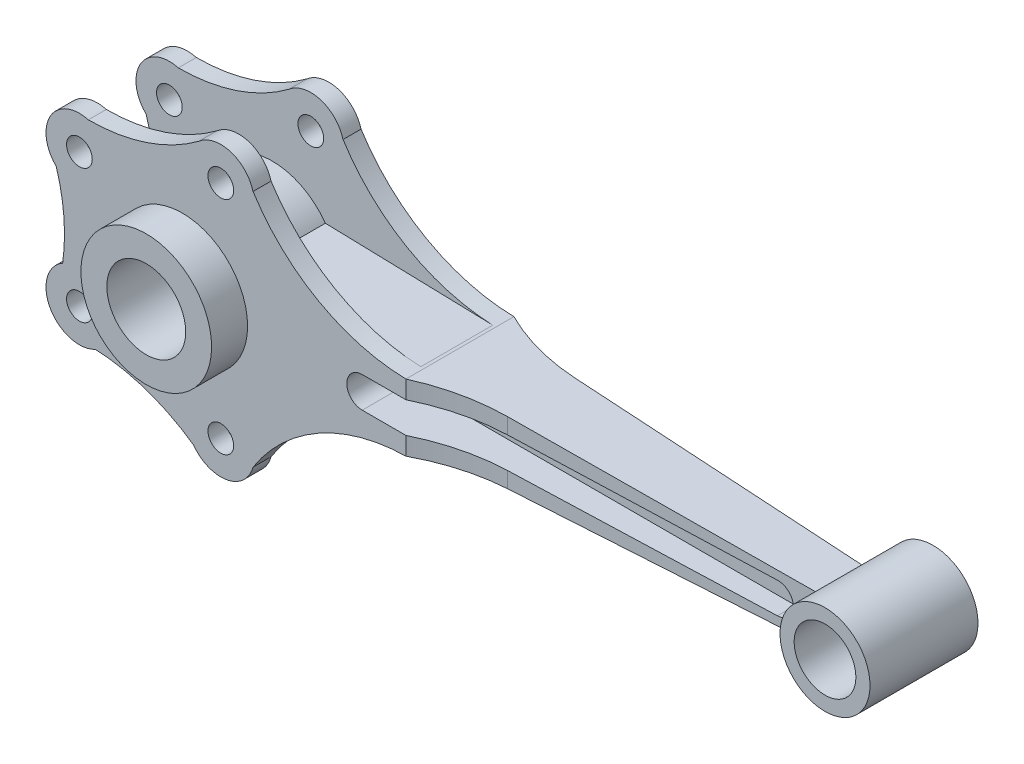
from build123d import *

# Parameters (mm, degrees)
SKETCH1_R           = 25.416099274
SKETCH1_R_2         = 15.345879333
BOSS_EXTRUDE3_DEPTH = 35
BOSS_EXTRUDE4_DEPTH = 21
CUT_EXTRUDE1_DEPTH  = 21
SKETCH1_7_R         = 17.5
SKETCH1_7_R_2       = 12
BOSS_EXTRUDE5_DEPTH = 21
BOSS_EXTRUDE6_START = 14
SKETCH1_8_R         = 5
BOSS_EXTRUDE6_DEPTH = 7
CUT_EXTRUDE2_DEPTH  = 18.5


with BuildPart() as part:
    # Sketch1 → Boss-Extrude3 (new body, symmetric)
    with BuildSketch(Plane.XY):
        Circle(SKETCH1_R)
        Circle(SKETCH1_R_2, mode=Mode.SUBTRACT)
    extrude(amount=BOSS_EXTRUDE3_DEPTH, both=True)

    # Sketch1_6 → Boss-Extrude4 (add, symmetric)
    with BuildSketch(Plane.XY):
        with BuildLine():
            ThreePointArc((234.99166898, -9), (232.5, 0), (234.99166898, 9))
            Line((234.99166898, 9), (87, 13))
            ThreePointArc((87, 13), (86.400314561, 13.01370903), (85.800764144, 13.032413604))
            Line((85.800764144, 13.032413604), (20.667586541, 14.792868853))
            ThreePointArc((20.667586541, 14.792868853), (24.199871215, 7.768161657), (25.416099274, 0))
            ThreePointArc((25.416099274, 0), (24.199871215, -7.768161657), (20.667586541, -14.792868853))
            Line((20.667586541, -14.792868853), (85.800764144, -13.032413604))
            ThreePointArc((85.800764144, -13.032413604), (86.400314561, -13.01370903), (87, -13))
            Line((87, -13), (234.99166898, -9))
        make_face()
    extrude(amount=BOSS_EXTRUDE4_DEPTH, both=True)

    # Sketch2 → Cut-Extrude1 (cut, symmetric)
    with BuildSketch(Plane(origin=(0, 0, 0), x_dir=(1, 0, 0), z_dir=(0, 1, 0))):
        with BuildLine():
            Line((118.656620919, 13.062509397), (234.99166898, 9))
            Line((234.99166898, 9), (234.99166898, 21))
            Line((234.99166898, 21), (87, 21))
            ThreePointArc((87, 21), (102.408517533, 15.35701958), (118.656620919, 13.062509397))
        make_face()
        with BuildLine():
            Line((87, -21), (234.99166898, -21))
            Line((234.99166898, -21), (234.99166898, -9))
            Line((234.99166898, -9), (118.656620919, -13.062509397))
            ThreePointArc((118.656620919, -13.062509397), (102.408517533, -15.35701958), (87, -21))
        make_face()
    extrude(amount=CUT_EXTRUDE1_DEPTH, both=True, mode=Mode.SUBTRACT)

    # Sketch1_7 → Boss-Extrude5 (add, symmetric)
    with BuildSketch(Plane.XY):
        with Locations((250, 0)):
            Circle(SKETCH1_7_R)
        with Locations((250, 0)):
            Circle(SKETCH1_7_R_2, mode=Mode.SUBTRACT)
    extrude(amount=BOSS_EXTRUDE5_DEPTH, both=True)

    # Sketch1_8 → Boss-Extrude6 (add)
    with BuildSketch(Plane.XY.offset(BOSS_EXTRUDE6_START)):
        with BuildLine():
            Line((20.667586541, 14.792868853), (85.800764144, 13.032413604))
            ThreePointArc((85.800764144, 13.032413604), (52.537254482, 22.523369258), (27.53882285, 46.431897657))
            ThreePointArc((27.53882285, 46.431897657), (18.775996279, 55.439527809), (6.484634563, 52.82285862))
            ThreePointArc((6.484634563, 52.82285862), (-13.863951623, 42.202436765), (-36.520978816, 38.525829777))
            ThreePointArc((-36.520978816, 38.525829777), (-51.292032009, 32.441274184), (-49.011059213, 16.629791258))
            ThreePointArc((-49.011059213, 16.629791258), (-46.024075038, 1.080135069), (-46.508202044, -14.746409188))
            ThreePointArc((-46.508202044, -14.746409188), (-51.333950201, -32.367226465), (-33.774741186, -37.412543656))
            ThreePointArc((-33.774741186, -37.412543656), (-13.740515927, -41.247010721), (4.414359967, -50.546139748))
            ThreePointArc((4.414359967, -50.546139748), (17.277164415, -55.799004736), (27.53882285, -46.431897657))
            ThreePointArc((27.53882285, -46.431897657), (52.537254482, -22.523369258), (85.800764144, -13.032413604))
            Line((85.800764144, -13.032413604), (20.667586541, -14.792868853))
            ThreePointArc((20.667586541, -14.792868853), (-25.416099274, 0), (20.667586541, 14.792868853))
        make_face()
        with Locations((15, -43)):
            Circle(SKETCH1_8_R, mode=Mode.SUBTRACT)
        with Locations((-40, -26)):
            Circle(SKETCH1_8_R, mode=Mode.SUBTRACT)
        with Locations((-40, 26)):
            Circle(SKETCH1_8_R, mode=Mode.SUBTRACT)
        with Locations((15, 43)):
            Circle(SKETCH1_8_R, mode=Mode.SUBTRACT)
    boss_extrude6 = extrude(amount=BOSS_EXTRUDE6_DEPTH)

    # Mirror1: Boss-Extrude6 across plane
    add(boss_extrude6.mirror(Plane.XY))

    # Sketch3 → Cut-Extrude2 (cut)
    with BuildSketch(Plane.XY.offset(21)):
        with BuildLine():
            Line((70, 6), (220, 6))
            ThreePointArc((220, 6), (226, 0), (220, -6))
            Line((220, -6), (70, -6))
            ThreePointArc((70, -6), (64, 0), (70, 6))
        make_face()
    cut_extrude2 = extrude(amount=-CUT_EXTRUDE2_DEPTH, mode=Mode.SUBTRACT)

    # Mirror2: Cut-Extrude2 across plane
    add(cut_extrude2.mirror(Plane.XY), mode=Mode.SUBTRACT)


solid = part.part
